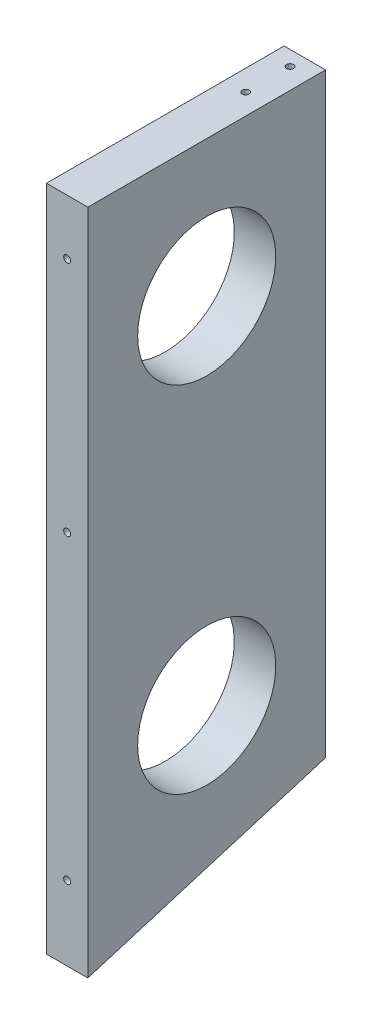
from build123d import *

# Parameters (mm, degrees)
SKETCH1_W           = 19.05
SKETCH1_H           = 270.042121692
BOSS_EXTRUDE1_DEPTH = 33.95
SKETCH2_W           = 19.05
SKETCH2_H           = 270.042121692
BOSS_EXTRUDE2_DEPTH = 75.35
BOSS_EXTRUDE3_DEPTH = 19.05
HOLE1_D             = 3.175
HOLE1_DEPTH         = 31.75
HOLE1_CSINK_D       = 10.16
HOLE1_CSINK_ANGLE   = 82
HOLE1_TIP           = 0.953866233
HOLE3_D             = 3.175
HOLE3_DEPTH         = 31.75
HOLE3_CSINK_D       = 10.16
HOLE3_CSINK_ANGLE   = 82
HOLE3_TIP           = 0.953866233
HOLE4_D             = 3.175
HOLE4_DEPTH         = 31.75
HOLE4_CSINK_D       = 10.16
HOLE4_CSINK_ANGLE   = 82
HOLE4_TIP           = 0.953866233
HOLE5_D             = 3.175
HOLE5_DEPTH         = 31.75
HOLE5_CSINK_D       = 10.16
HOLE5_CSINK_ANGLE   = 82
HOLE5_TIP           = 0.953866233
HOLE6_D             = 63.5
HOLE6_DEPTH         = 19.05


with BuildPart() as part:
    # Sketch1 → Boss-Extrude1 (new body)
    with BuildSketch(Plane.XY):
        with Locations((-124.004465969, -292.321060846)):
            Rectangle(SKETCH1_W, SKETCH1_H)
    extrude(amount=BOSS_EXTRUDE1_DEPTH)

    # Sketch2 → Boss-Extrude2 (add)
    with BuildSketch(Plane.XY.offset(33.95)):
        with Locations((-124.004465969, -292.321060846)):
            Rectangle(SKETCH2_W, SKETCH2_H)
    extrude(amount=BOSS_EXTRUDE2_DEPTH)

    # Sketch3 → Boss-Extrude3 (add, through all)
    with BuildSketch(Plane.ZY.offset(133.529465969)):
        Polygon((109.3, -427.342121692), (109.3, -464.26606302), (0, -431.185843453), (0, -427.342121692), align=None)
    extrude(amount=-BOSS_EXTRUDE3_DEPTH)

    # Hole1
    with Locations(Plane(origin=(-124.004465969, 10.424290059, 122), x_dir=(-1, 0, 0), z_dir=(0, 0, 1))):
        with Locations((113.649999994, 128.807623392), (113.649999994, 23.940956725), (-94.599999994, 161.374290059), (94.599999994, 161.374290059), (0, 161.374290059), (0, 193.124290059), (0, 440.553783621), (0, 301.970350905), (40.979166666, 301.970350905), (166.795833328, 301.970350905), (207.774999994, 440.553783621), (207.774999994, 333.02141023), (207.774999994, 225.48903684), (207.774999994, 137.424290059), (207.774999994, 10.424290059), (-207.774999994, 10.424290059), (-207.774999994, 137.424290059), (-207.774999994, 225.48903684), (-207.774999994, 333.02141023), (-207.774999994, 440.553783621), (-166.795833328, 301.970350905), (-40.979166666, 301.970350905), (-113.649999994, 23.940956725), (-113.649999994, 128.807623392)):
            CounterSinkHole(HOLE1_D / 2, HOLE1_CSINK_D / 2, depth=HOLE1_DEPTH, counter_sink_angle=HOLE1_CSINK_ANGLE)
            with Locations((0, 0, -(HOLE1_DEPTH + HOLE1_TIP / 2))):  # 118° drill point
                Cone(0, HOLE1_D / 2, HOLE1_TIP, mode=Mode.SUBTRACT)

    # Hole3
    with Locations(Plane(origin=(-124.004465969, -144.6, -155.286738577), x_dir=(-1, 0, 0), z_dir=(0, 1, 0))):
        with Locations((0, 162.086738577), (0, 182.486738577)):
            CounterSinkHole(HOLE3_D / 2, HOLE3_CSINK_D / 2, depth=HOLE3_DEPTH, counter_sink_angle=HOLE3_CSINK_ANGLE)
            with Locations((0, 0, -(HOLE3_DEPTH + HOLE3_TIP / 2))):  # 118° drill point
                Cone(0, HOLE3_D / 2, HOLE3_TIP, mode=Mode.SUBTRACT)

    # Hole4
    with Locations(Plane(origin=(-124.004465969, 10.424290059, -12.7), x_dir=(1, 0, 0), z_dir=(0, 0, -1))):
        with Locations((-207.774999994, 333.02141023), (-207.774999994, 225.48903684), (-207.774999994, 137.424290059), (-172.166666661, 4.074290059), (-146.083333327, 4.074290059), (-94.599999994, 161.374290059), (0, 161.374290059), (94.599999994, 161.374290059), (146.083333327, 4.074290059), (172.166666661, 4.074290059), (207.774999994, 137.424290059), (207.774999994, 225.48903684), (207.774999994, 333.02141023), (166.795833328, 301.970350905), (40.979166666, 301.970350905), (-40.979166666, 301.970350905), (-166.795833328, 301.970350905), (0, 193.124290059), (0, 301.970350905), (0, 412.366411751), (-126.349999994, 106.824290059), (-126.349999994, 58.624290059), (126.349999994, 58.624290059), (126.349999994, 106.824290059)):
            CounterSinkHole(HOLE4_D / 2, HOLE4_CSINK_D / 2, depth=HOLE4_DEPTH, counter_sink_angle=HOLE4_CSINK_ANGLE)
            with Locations((0, 0, -(HOLE4_DEPTH + HOLE4_TIP / 2))):  # 118° drill point
                Cone(0, HOLE4_D / 2, HOLE4_TIP, mode=Mode.SUBTRACT)

    # Hole5
    with Locations(Plane(origin=(-124.004465969, -363.229637966, -268.375064111), x_dir=(1, 0, 0), z_dir=(0, -0.957123977, -0.289678603))):
        with Locations((207.774999994, 613.051808534), (-207.774999994, 613.051808534), (-207.774999994, 456.277103296), (-207.774999994, 769.826513772), (-108.649999997, 456.277103296), (-108.649999997, 630.126513772), (-108.649999997, 769.826513772), (-207.774999994, 362.200879148), (-207.774999994, 305.10273792), (0, 305.10273792), (0, 362.200879148), (207.774999994, 305.10273792), (207.774999994, 362.200879148), (108.649999997, 769.826513772), (108.649999997, 630.126513772), (108.649999997, 456.277103296), (207.774999994, 769.826513772), (207.774999994, 456.277103296)):
            CounterSinkHole(HOLE5_D / 2, HOLE5_CSINK_D / 2, depth=HOLE5_DEPTH, counter_sink_angle=HOLE5_CSINK_ANGLE)
            with Locations((0, 0, -(HOLE5_DEPTH + HOLE5_TIP / 2))):  # 118° drill point
                Cone(0, HOLE5_D / 2, HOLE5_TIP, mode=Mode.SUBTRACT)

    # Hole6
    with Locations(Plane.ZY.offset(133.529465969)):
        with Locations((54.65, -220.048030423), (54.65, -383.056061933)):
            Hole(HOLE6_D / 2, depth=HOLE6_DEPTH)


solid = part.part
